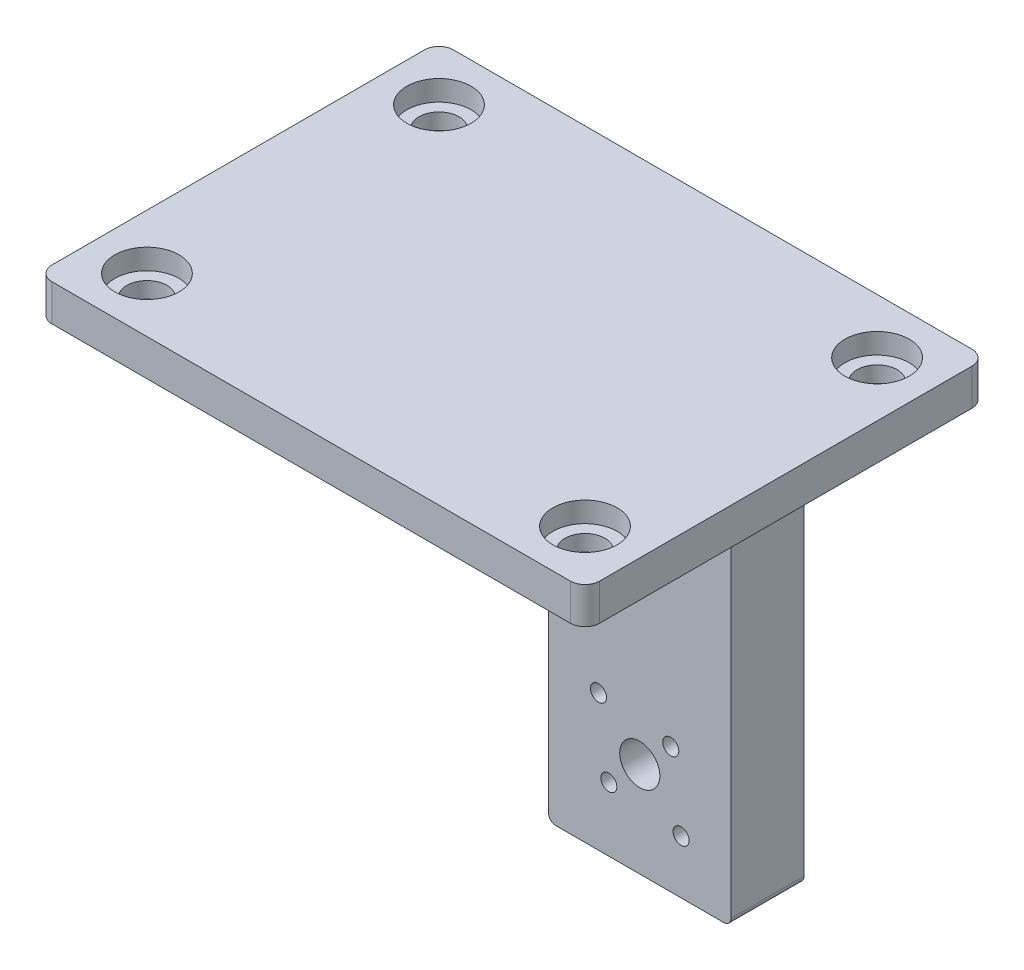
from build123d import *

# Parameters (mm, degrees)
SKETCH1_W           = 75
SKETCH1_H           = 55
BOSS_EXTRUDE1_DEPTH = 5
SKETCH2_R           = 2.75
CUT_EXTRUDE1_DEPTH  = 6
FILLET5_R           = 2
SKETCH6_R           = 4.4
CUT_EXTRUDE3_DEPTH  = 2.8
SKETCH7_W           = 25
SKETCH7_H           = 10
BOSS_EXTRUDE2_DEPTH = 70
SKETCH8_W           = 7
SKETCH8_H           = 30
CUT_EXTRUDE4_DEPTH  = 51
SKETCH11_W          = 25
SKETCH11_H          = 7
BOSS_EXTRUDE3_DEPTH = 30
FILLET6_R           = 2
FILLET7_R           = 1
SKETCH17_R          = 2.75
SKETCH17_R_2        = 1.1
CUT_EXTRUDE5_DEPTH  = 56
SKETCH18_R          = 2.5
CUT_EXTRUDE6_DEPTH  = 7


with BuildPart() as part:
    # Sketch1 → Boss-Extrude1 (new body)
    with BuildSketch(Plane(origin=(0, 0, 0), x_dir=(1, 0, 0), z_dir=(0, 1, 0))):
        Rectangle(SKETCH1_W, SKETCH1_H)
    extrude(amount=BOSS_EXTRUDE1_DEPTH)

    # Sketch2 → Cut-Extrude1 (cut, through all)
    with BuildSketch(Plane(origin=(0, 5, 0), x_dir=(1, 0, 0), z_dir=(0, 1, 0))):
        with Locations((-30, 20)):
            Circle(SKETCH2_R)
        with Locations((-30, -20)):
            Circle(SKETCH2_R)
    cut_extrude1 = extrude(amount=-CUT_EXTRUDE1_DEPTH, mode=Mode.SUBTRACT)

    # Mirror1: Cut-Extrude1 across plane
    add(cut_extrude1.mirror(Plane(origin=(0, 0, 0), x_dir=(0, 0, 1), z_dir=(1, 0, 0))), mode=Mode.SUBTRACT)

    # Fillet5
    fillet5_edges = [part.edges().sort_by_distance(p)[0] for p in [
        (37.5, 2.5, 27.5),
        (-37.5, 2.5, 27.5),
        (-37.5, 2.5, -27.5),
        (37.5, 2.5, -27.5),
    ]]
    fillet(fillet5_edges, radius=FILLET5_R)

    # Sketch6 → Cut-Extrude3 (cut)
    with BuildSketch(Plane(origin=(0, 5, 0), x_dir=(1, 0, 0), z_dir=(0, 1, 0))):
        with Locations((-30, 20)):
            Circle(SKETCH6_R)
        with Locations((-30, -20)):
            Circle(SKETCH6_R)
        with Locations((30, 20)):
            Circle(SKETCH6_R)
        with Locations((30, -20)):
            Circle(SKETCH6_R)
    extrude(amount=-CUT_EXTRUDE3_DEPTH, mode=Mode.SUBTRACT)

    # Sketch7 → Boss-Extrude2 (add)
    with BuildSketch(Plane.XZ):
        with Locations((0, -22.5)):
            Rectangle(SKETCH7_W, SKETCH7_H)
    extrude(amount=BOSS_EXTRUDE2_DEPTH)

    # Sketch8 → Cut-Extrude4 (cut, through all)
    with BuildSketch(Plane.ZY.offset(12.5)):
        with Locations((-21, -55)):
            Rectangle(SKETCH8_W, SKETCH8_H)
    extrude(amount=-CUT_EXTRUDE4_DEPTH, mode=Mode.SUBTRACT)

    # Sketch11 → Boss-Extrude3 (add)
    with BuildSketch(Plane.XZ.offset(40)):
        with Locations((0, -21)):
            Rectangle(SKETCH11_W, SKETCH11_H)
    extrude(amount=BOSS_EXTRUDE3_DEPTH)

    # Fillet6
    fillet6_edges = [part.edges().sort_by_distance(p)[0] for p in [
        (-12.5, 0, -22.5),
        (12.5, 0, -22.5),
        (0, 0, -17.5),
    ]]
    fillet(fillet6_edges, radius=FILLET6_R)

    # Fillet7
    fillet7_edges = [part.edges().sort_by_distance(p)[0] for p in [
        (12.5, -70, -22.5),
        (-12.5, -70, -22.5),
    ]]
    fillet(fillet7_edges, radius=FILLET7_R)

    # Sketch17 → Cut-Extrude5 (cut, through all)
    with BuildSketch(Plane(origin=(0, 0, -27.5), x_dir=(-1, 0, 0), z_dir=(0, 0, -1))):
        with Locations((0, -57)):
            Circle(SKETCH17_R)
        with Locations((5.656854249, -51.343145751)):
            Circle(SKETCH17_R_2)
        with Locations((-5.656854249, -62.656854249)):
            Circle(SKETCH17_R_2)
        with Locations((-4.242640687, -52.757359313)):
            Circle(SKETCH17_R_2)
        with Locations((4.242640687, -61.242640687)):
            Circle(SKETCH17_R_2)
    extrude(amount=-CUT_EXTRUDE5_DEPTH, mode=Mode.SUBTRACT)

    # Sketch18 → Cut-Extrude6 (cut)
    with BuildSketch(Plane(origin=(0, 0, -27.5), x_dir=(-1, 0, 0), z_dir=(0, 0, -1))):
        with Locations((-4.242640687, -52.757359313)):
            Circle(SKETCH18_R)
        with Locations((-5.656854249, -62.656854249)):
            Circle(SKETCH18_R)
        with Locations((5.656854249, -51.343145751)):
            Circle(SKETCH18_R)
        with Locations((4.242640687, -61.242640687)):
            Circle(SKETCH18_R)
    extrude(amount=-CUT_EXTRUDE6_DEPTH, mode=Mode.SUBTRACT)


solid = part.part
